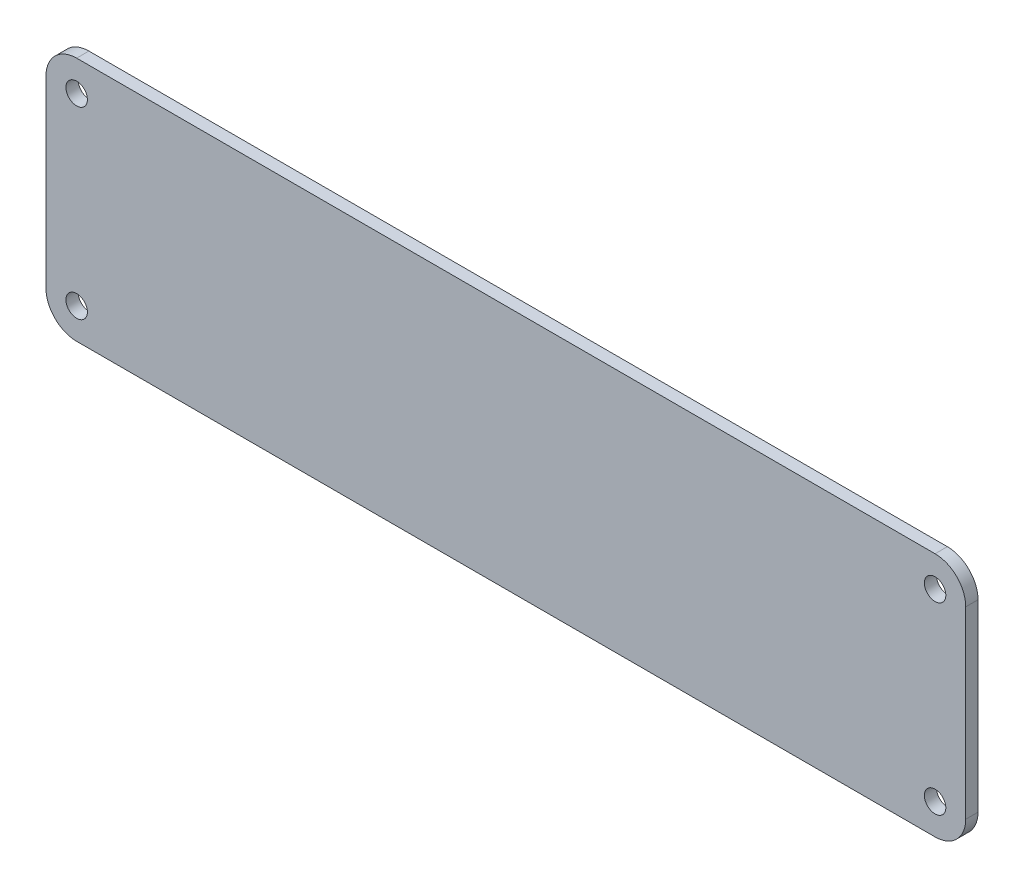
from build123d import *

# Parameters (mm, degrees)
SKETCH1_W           = 150
SKETCH1_H           = 40
BOSS_EXTRUDE1_DEPTH = 2
SKETCH2_R           = 1.75
CUT_EXTRUDE1_DEPTH  = 3
FILLET1_R           = 5


with BuildPart() as part:
    # Sketch1 → Boss-Extrude1 (new body)
    with BuildSketch(Plane.XY):
        Rectangle(SKETCH1_W, SKETCH1_H)
    extrude(amount=BOSS_EXTRUDE1_DEPTH)

    # Sketch2 → Cut-Extrude1 (cut, through all)
    with BuildSketch(Plane.XY.offset(2)):
        with Locations((-70, 15)):
            Circle(SKETCH2_R)
        with Locations((-70, -15)):
            Circle(SKETCH2_R)
        with Locations((70, -15)):
            Circle(SKETCH2_R)
        with Locations((70, 15)):
            Circle(SKETCH2_R)
    extrude(amount=-CUT_EXTRUDE1_DEPTH, mode=Mode.SUBTRACT)

    # Fillet1
    fillet1_edges = [part.edges().sort_by_distance(p)[0] for p in [
        (-75, 20, 1),
        (75, 20, 1),
        (75, -20, 1),
        (-75, -20, 1),
    ]]
    fillet(fillet1_edges, radius=FILLET1_R)


solid = part.part
